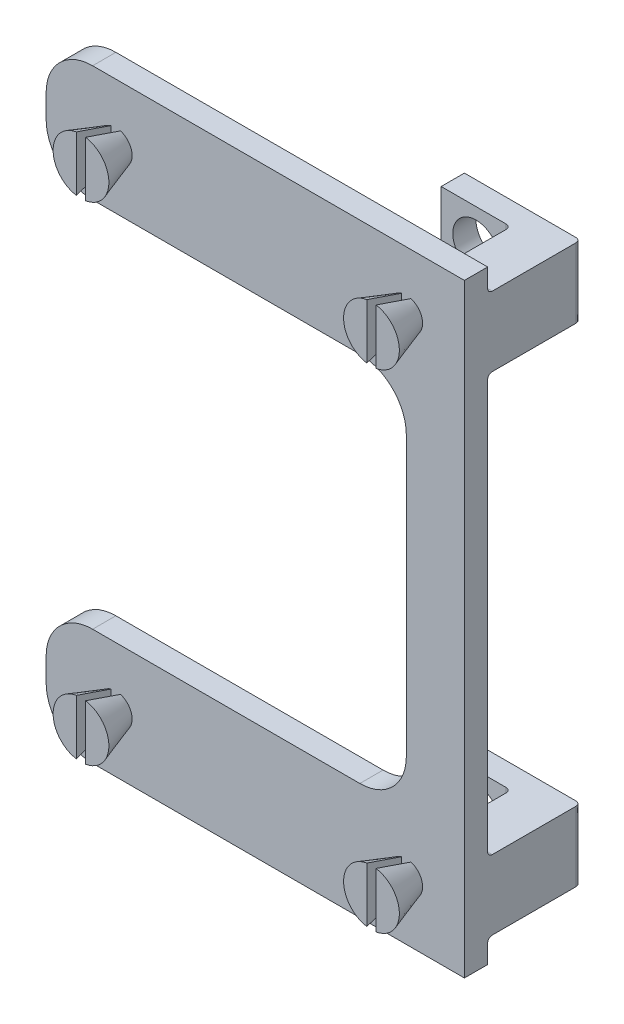
from build123d import *

# Parameters (mm, degrees)
IZIM1_W                     = 25
IZIM1_H                     = 26
Y_KSEKLIK_EKSTR_ZYON1_DEPTH = 1
IZIM12_W                    = 0.4
IZIM12_H                    = 1.5
KES_EKSTR_ZYON2_DEPTH       = 12
KES_EKSTR_ZYON2_DEPTH_BACK  = 25.3
IZIM13_W                    = 20
IZIM13_H                    = 16
KES_EKSTR_ZYON4_DEPTH       = 5
KES_EKSTR_ZYON4_DEPTH_BACK  = 4
RADYUS1_R                   = 2
IZIM14_W                    = 7
IZIM14_H                    = 26
KES_EKSTR_ZYON5_DEPTH       = 3
KES_EKSTR_ZYON5_DEPTH_BACK  = 3
RADYUS2_R                   = 2
IZIM17_W                    = 4
IZIM17_H                    = 3
Y_KSEKLIK_EKSTR_ZYON2_DEPTH = 2
IZIM18_W                    = 4
IZIM18_H                    = 3
Y_KSEKLIK_EKSTR_ZYON3_DEPTH = 1
IZIM19_R                    = 1
KES_EKSTR_ZYON6_DEPTH       = 1
RADYUS3_R                   = 0.2
RADYUS3_OF_AYNALAMA2_R      = 0.2


with BuildPart() as part:
    # Çizim1 → Yükseklik-Ekstrüzyon1 (new body)
    with BuildSketch(Plane.XY):
        Rectangle(IZIM1_W, IZIM1_H)
    extrude(amount=Y_KSEKLIK_EKSTR_ZYON1_DEPTH)

    # Çizim9 → Döndür1 (revolve)
    with BuildSketch(Plane(origin=(0, 10.5, 0), x_dir=(1, 0, 0), z_dir=(0, 1, 0))):
        Polygon((-2.5, -1), (-2.5, -2.5), (-3.7, -2.5), (-3.2, -1), align=None)
    d_nd_r1 = revolve(axis=Axis((-2.5, 10.5, 1), (0, 0, 1)))

    # Çizim11 → Döndür2 (revolve)
    with BuildSketch(Plane(origin=(0, 10.5, 0), x_dir=(1, 0, 0), z_dir=(0, 1, 0))):
        Polygon((10, -1), (10, -2.5), (8.8, -2.5), (9.3, -1), align=None)
    d_nd_r2 = revolve(axis=Axis((10, 10.5, 1), (0, 0, 1)))

    # Aynalama1: Döndür1, Döndür2 across plane
    add(d_nd_r1.mirror(Plane.ZX))
    add(d_nd_r2.mirror(Plane.ZX))

    # Çizim12 → Kes-Ekstrüzyon2 (cut, two sides)
    with BuildSketch(Plane(origin=(0, 10.5, 0), x_dir=(1, 0, 0), z_dir=(0, 1, 0))) as kes_ekstr_zyon2_sk:
        with Locations((-2.5, -1.75)):
            Rectangle(IZIM12_W, IZIM12_H)
        with Locations((10, -1.75)):
            Rectangle(IZIM12_W, IZIM12_H)
    extrude(amount=KES_EKSTR_ZYON2_DEPTH, mode=Mode.SUBTRACT)
    extrude(kes_ekstr_zyon2_sk.sketch, amount=-KES_EKSTR_ZYON2_DEPTH_BACK, mode=Mode.SUBTRACT)

    # Çizim13 → Kes-Ekstrüzyon4 (cut, two sides)
    with BuildSketch(Plane.XY) as kes_ekstr_zyon4_sk:
        Rectangle(IZIM13_W, IZIM13_H)
    extrude(amount=KES_EKSTR_ZYON4_DEPTH, mode=Mode.SUBTRACT)
    extrude(kes_ekstr_zyon4_sk.sketch, amount=-KES_EKSTR_ZYON4_DEPTH_BACK, mode=Mode.SUBTRACT)

    # Radyus1
    radyus1_edges = [part.edges().sort_by_distance(p)[0] for p in [
        (10, 8, 0.5),
        (-10, 8, 0.5),
        (-10, -8, 0.5),
        (10, -8, 0.5),
    ]]
    fillet(radyus1_edges, radius=RADYUS1_R)

    # Çizim14 → Kes-Ekstrüzyon5 (cut, two sides)
    with BuildSketch(Plane.XY) as kes_ekstr_zyon5_sk:
        with Locations((-9, 0)):
            Rectangle(IZIM14_W, IZIM14_H)
    extrude(amount=KES_EKSTR_ZYON5_DEPTH, mode=Mode.SUBTRACT)
    extrude(kes_ekstr_zyon5_sk.sketch, amount=-KES_EKSTR_ZYON5_DEPTH_BACK, mode=Mode.SUBTRACT)

    # Radyus2
    radyus2_edges = [part.edges().sort_by_distance(p)[0] for p in [
        (-5.5, -8, 0.5),
        (-5.5, 13, 0.5),
        (-5.5, -13, 0.5),
        (-5.5, 8, 0.5),
    ]]
    fillet(radyus2_edges, radius=RADYUS2_R)

    # Çizim17 → Yükseklik-Ekstrüzyon2 (add)
    with BuildSketch(Plane(origin=(10.5, 0, 0), x_dir=(0, 0, -1), z_dir=(1, 0, 0))):
        with Locations((2, 10.5)):
            Rectangle(IZIM17_W, IZIM17_H)
    y_kseklik_ekstr_zyon2 = extrude(amount=Y_KSEKLIK_EKSTR_ZYON2_DEPTH)

    # Çizim18 → Yükseklik-Ekstrüzyon3 (add)
    with BuildSketch(Plane(origin=(0, 0, -4), x_dir=(-1, 0, 0), z_dir=(0, 0, -1))):
        with Locations((-9.5, 10.5)):
            Rectangle(IZIM18_W, IZIM18_H)
    y_kseklik_ekstr_zyon3 = extrude(amount=-Y_KSEKLIK_EKSTR_ZYON3_DEPTH)

    # Çizim19 → Kes-Ekstrüzyon6 (cut)
    with BuildSketch(Plane(origin=(0, 0, -4), x_dir=(-1, 0, 0), z_dir=(0, 0, -1))):
        with Locations((-9, 10.5)):
            Circle(IZIM19_R)
    kes_ekstr_zyon6 = extrude(amount=-KES_EKSTR_ZYON6_DEPTH, mode=Mode.SUBTRACT)

    # Radyus3
    radyus3_edges = [part.edges().sort_by_distance(p)[0] for p in [
        (10.5, 10.5, 0),
        (11.5, 12, 0),
        (11.5, 9, 0),
        (12.5, 10.5, -4),
        (10.5, 10.5, -3),
    ]]
    fillet(radyus3_edges, radius=RADYUS3_R)

    # Aynalama2: Yükseklik-Ekstrüzyon2, Yükseklik-Ekstrüzyon3, Kes-Ekstrüzyon6 across plane
    add(y_kseklik_ekstr_zyon2.mirror(Plane.ZX))
    add(y_kseklik_ekstr_zyon3.mirror(Plane.ZX))
    add(kes_ekstr_zyon6.mirror(Plane.ZX), mode=Mode.SUBTRACT)

    # Radyus3 of Aynalama2
    radyus3_of_aynalama2_edges = [part.edges().sort_by_distance(p)[0] for p in [
        (10.5, -10.5, 0),
        (11.5, -12, 0),
        (11.5, -9, 0),
        (12.5, -10.5, -4),
        (10.5, -10.5, -3),
    ]]
    fillet(radyus3_of_aynalama2_edges, radius=RADYUS3_OF_AYNALAMA2_R)


solid = part.part
